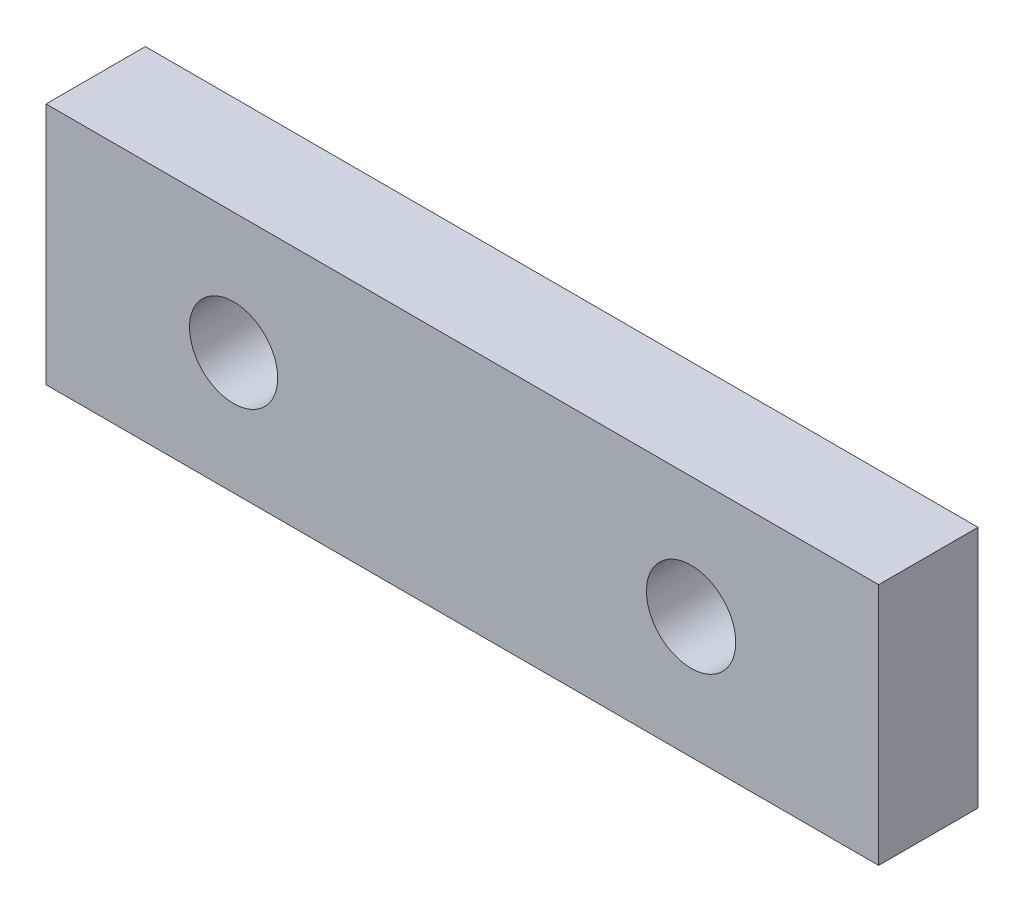
from build123d import *

# Parameters (mm, degrees)
SKETCH1_W           = 80.899
SKETCH1_H           = 23.622
SKETCH1_R           = 4.283301185
SKETCH1_R_2         = 4.337670236
BOSS_EXTRUDE1_DEPTH = 9.652


with BuildPart() as part:
    # Sketch1 → Boss-Extrude1 (new body)
    with BuildSketch(Plane.XY):
        Rectangle(SKETCH1_W, SKETCH1_H)
        with Locations((-22.225, 0)):
            Circle(SKETCH1_R, mode=Mode.SUBTRACT)
        with Locations((22.225, 0)):
            Circle(SKETCH1_R_2, mode=Mode.SUBTRACT)
    extrude(amount=BOSS_EXTRUDE1_DEPTH)


solid = part.part
